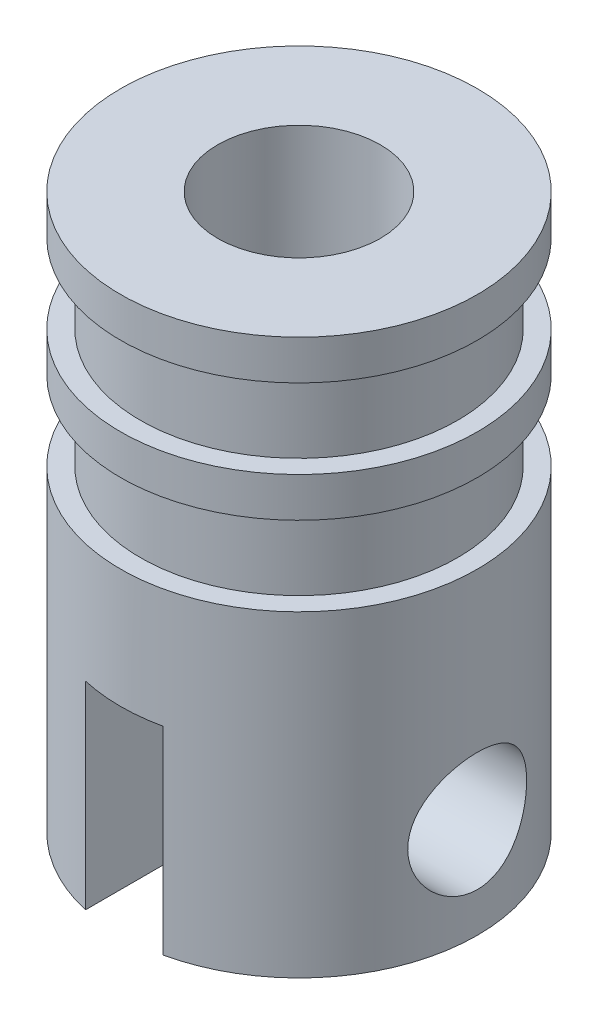
from build123d import *

# Parameters (mm, degrees)
CROQUIS3_W                 = 1.967221418
CROQUIS3_H                 = 9
CORTAR_EXTRUIR1_DEPTH      = 5
CROQUIS4_R                 = 2.05
CORTAR_EXTRUIR2_DEPTH      = 9
CROQUIS7_R                 = 1.5
CORTAR_EXTRUIR3_DEPTH      = 6.467221418
CORTAR_EXTRUIR3_DEPTH_BACK = 4.532778582
ESCALA1_SCALE              = 7


with BuildPart() as part:
    # Croquis2 → Revolución4 (revolve)
    with BuildSketch(Plane.XY):
        Polygon((0, 14), (-4.5, 14), (-4.5, 13), (-4, 13), (-4, 11), (-4.5, 11), (-4.5, 10), (-4, 10), (-4, 8), (-4.5, 8), (-4.5, 0), (0, 0), align=None)
    revolve(axis=Axis((0, 0, 0), (0, 1, 0)))

    # Croquis3 → Cortar-Extruir1 (cut)
    with BuildSketch(Plane.XZ):
        with Locations((-0.016389291, 0)):
            Rectangle(CROQUIS3_W, CROQUIS3_H)
    extrude(amount=-CORTAR_EXTRUIR1_DEPTH, mode=Mode.SUBTRACT)

    # Croquis4 → Cortar-Extruir2 (cut)
    with BuildSketch(Plane(origin=(0, 14, 0), x_dir=(1, 0, 0), z_dir=(0, 1, 0))):
        Circle(CROQUIS4_R)
    extrude(amount=-CORTAR_EXTRUIR2_DEPTH, mode=Mode.SUBTRACT)

    # Croquis7 → Cortar-Extruir3 (cut, two sides)
    with BuildSketch(Plane.ZY.offset(-0.967221418)) as cortar_extruir3_sk:
        with Locations((0, 2.5)):
            Circle(CROQUIS7_R)
    extrude(amount=CORTAR_EXTRUIR3_DEPTH, mode=Mode.SUBTRACT)
    extrude(cortar_extruir3_sk.sketch, amount=-CORTAR_EXTRUIR3_DEPTH_BACK, mode=Mode.SUBTRACT)


with BuildPart() as part_1:
    # Escala1: scaled about (0.00203743, 7.224994078, -4.8862e-05)
    add(part.part.scale(ESCALA1_SCALE).moved(Location((-0.01222458, -43.349964468, 0.000293172))))


solid = part_1.part
